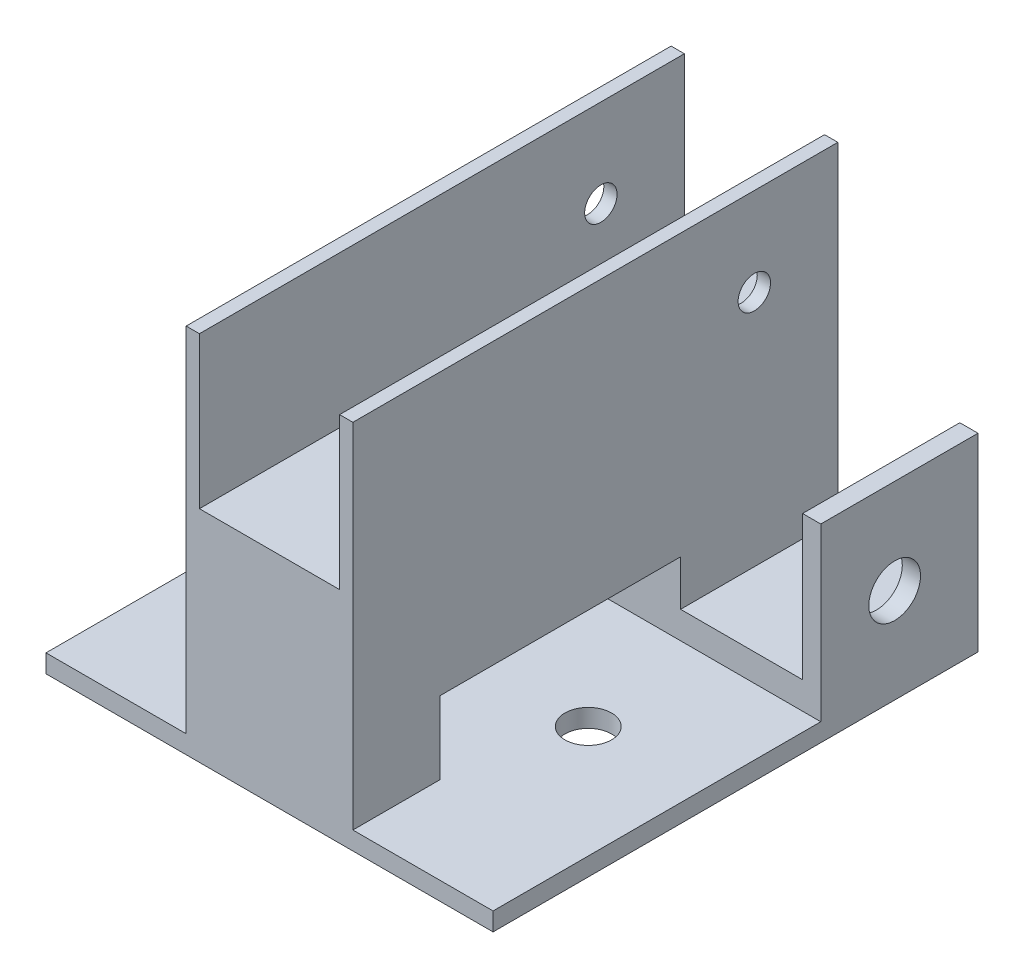
from build123d import *

# Parameters (mm, degrees)
SKETCH1_W           = 22
SKETCH1_H           = 64
BOSS_EXTRUDE2_DEPTH = 49
SKETCH3_W           = 18.5
SKETCH3_H           = 64
CUT_EXTRUDE1_DEPTH  = 20
SKETCH4_R           = 2.14
CUT_EXTRUDE2_DEPTH  = 28
SKETCH5_W           = 64
SKETCH5_H           = 6
BOSS_EXTRUDE3_DEPTH = 18.5
SKETCH6_W           = 2.4
SKETCH6_H           = 64
BOSS_EXTRUDE4_DEPTH = 19
SKETCH7_R           = 3.41
CUT_EXTRUDE3_DEPTH  = 13
SKETCH8_W           = 64
SKETCH8_H           = 6
BOSS_EXTRUDE5_DEPTH = 18.5
SKETCH9_W           = 2.4
SKETCH9_H           = 64
BOSS_EXTRUDE6_DEPTH = 19
SKETCH10_R          = 3.41
CUT_EXTRUDE4_DEPTH  = 13.550505831
SKETCH12_R          = 3.075953135
CUT_EXTRUDE6_DEPTH  = 50
CUT_EXTRUDE7_REACH  = 42.5
SKETCH13_W          = 31.75
SKETCH13_H          = 6
SKETCH15_W          = 2.4
SKETCH15_H          = 43.25
CUT_EXTRUDE8_DEPTH  = 19
SKETCH16_W          = 2.4
SKETCH16_H          = 43.25
CUT_EXTRUDE9_DEPTH  = 19
SKETCH17_R          = 3.075953135
SKETCH17_W          = 18.5
SKETCH17_H          = 11.5
CUT_EXTRUDE10_DEPTH = 3.6


with BuildPart() as part:
    # Sketch1 → Boss-Extrude2 (new body)
    with BuildSketch(Plane(origin=(0, 0, 0), x_dir=(1, 0, 0), z_dir=(0, 1, 0))):
        Rectangle(SKETCH1_W, SKETCH1_H)
    extrude(amount=BOSS_EXTRUDE2_DEPTH)

    # Sketch3 → Cut-Extrude1 (cut)
    with BuildSketch(Plane(origin=(0, 49, 0), x_dir=(1, 0, 0), z_dir=(0, 1, 0))):
        Rectangle(SKETCH3_W, SKETCH3_H)
    extrude(amount=-CUT_EXTRUDE1_DEPTH, mode=Mode.SUBTRACT)

    # Sketch4 → Cut-Extrude2 (cut)
    with BuildSketch(Plane(origin=(11, 0, 0), x_dir=(0, 0, -1), z_dir=(1, 0, 0))):
        with Locations((20.979041052, 37.382)):
            Circle(SKETCH4_R)
    extrude(amount=-CUT_EXTRUDE2_DEPTH, mode=Mode.SUBTRACT)

    # Sketch5 → Boss-Extrude3 (add)
    with BuildSketch(Plane(origin=(11, 0, 0), x_dir=(0, 0, -1), z_dir=(1, 0, 0))):
        with Locations((0, 3)):
            Rectangle(SKETCH5_W, SKETCH5_H)
    extrude(amount=BOSS_EXTRUDE3_DEPTH)

    # Sketch6 → Boss-Extrude4 (add)
    with BuildSketch(Plane(origin=(0, 6, 0), x_dir=(1, 0, 0), z_dir=(0, 1, 0))):
        with Locations((28.3, 0)):
            Rectangle(SKETCH6_W, SKETCH6_H)
    extrude(amount=BOSS_EXTRUDE4_DEPTH)

    # Sketch7 → Cut-Extrude3 (cut)
    with BuildSketch(Plane(origin=(29.5, 0, 0), x_dir=(0, 0, -1), z_dir=(1, 0, 0))):
        with Locations((21, 12.5)):
            Circle(SKETCH7_R)
    extrude(amount=-CUT_EXTRUDE3_DEPTH, mode=Mode.SUBTRACT)

    # Sketch8 → Boss-Extrude5 (add)
    with BuildSketch(Plane.ZY.offset(11)):
        with Locations((0, 3)):
            Rectangle(SKETCH8_W, SKETCH8_H)
    extrude(amount=BOSS_EXTRUDE5_DEPTH)

    # Sketch9 → Boss-Extrude6 (add)
    with BuildSketch(Plane(origin=(0, 6, 0), x_dir=(1, 0, 0), z_dir=(0, 1, 0))):
        with Locations((-28.3, 0)):
            Rectangle(SKETCH9_W, SKETCH9_H)
    extrude(amount=BOSS_EXTRUDE6_DEPTH)

    # Sketch10 → Cut-Extrude4 (cut)
    with BuildSketch(Plane.ZY.offset(29.5)):
        with Locations((-21, 12.5)):
            Circle(SKETCH10_R)
    extrude(amount=-CUT_EXTRUDE4_DEPTH, mode=Mode.SUBTRACT)

    # Sketch12 → Cut-Extrude6 (cut, through all)
    with BuildSketch(Plane(origin=(0, 0, 0), x_dir=(-1, 0, 0), z_dir=(0, -1, 0))):
        with Locations((14.6918, -4.628600023)):
            Circle(SKETCH12_R)
        with Locations((-14.6918, -4.628600023)):
            Circle(SKETCH12_R)
    extrude(amount=-CUT_EXTRUDE6_DEPTH, mode=Mode.SUBTRACT)

    # Sketch13 → Cut-Extrude7 (cut, up to next)
    with BuildSketch(Plane.ZY.offset(11), mode=Mode.PRIVATE) as cut_extrude7_sk1:
        with Locations((4.625, 9)):
            Rectangle(SKETCH13_W, SKETCH13_H)
    cut_extrude7_tool1 = extrude(cut_extrude7_sk1.sketch, amount=-CUT_EXTRUDE7_REACH, mode=Mode.PRIVATE) & part.part
    add(cut_extrude7_tool1.solids().sort_by_distance((-11, 9, 4.625))[0], mode=Mode.SUBTRACT)

    # Sketch15 → Cut-Extrude8 (cut)
    with BuildSketch(Plane(origin=(0, 25, 0), x_dir=(1, 0, 0), z_dir=(0, 1, 0))):
        with Locations((-28.3, -10.375)):
            Rectangle(SKETCH15_W, SKETCH15_H)
    extrude(amount=-CUT_EXTRUDE8_DEPTH, mode=Mode.SUBTRACT)

    # Sketch16 → Cut-Extrude9 (cut)
    with BuildSketch(Plane(origin=(0, 25, 0), x_dir=(1, 0, 0), z_dir=(0, 1, 0))):
        with Locations((28.3, -10.375)):
            Rectangle(SKETCH16_W, SKETCH16_H)
    extrude(amount=-CUT_EXTRUDE9_DEPTH, mode=Mode.SUBTRACT)

    # Sketch17 → Cut-Extrude10 (cut)
    with BuildSketch(Plane(origin=(0, 6, 0), x_dir=(1, 0, 0), z_dir=(0, 1, 0))):
        Polygon((-27.1, 11.25), (-29.5, 11.25), (-29.5, -20.5), (-11, -20.5), (11, -20.5), (29.5, -20.5), (29.5, 11.25), (27.1, 11.25), (11, 11.25), (-11, 11.25), align=None)
        with Locations((-14.6918, -4.628600023)):
            Circle(SKETCH17_R, mode=Mode.SUBTRACT)
        with Locations((14.6918, -4.628600023)):
            Circle(SKETCH17_R, mode=Mode.SUBTRACT)
        with Locations((-20.25, -26.25)):
            Rectangle(SKETCH17_W, SKETCH17_H)
        with Locations((20.25, -26.25)):
            Rectangle(SKETCH17_W, SKETCH17_H)
    extrude(amount=-CUT_EXTRUDE10_DEPTH, mode=Mode.SUBTRACT)


solid = part.part
